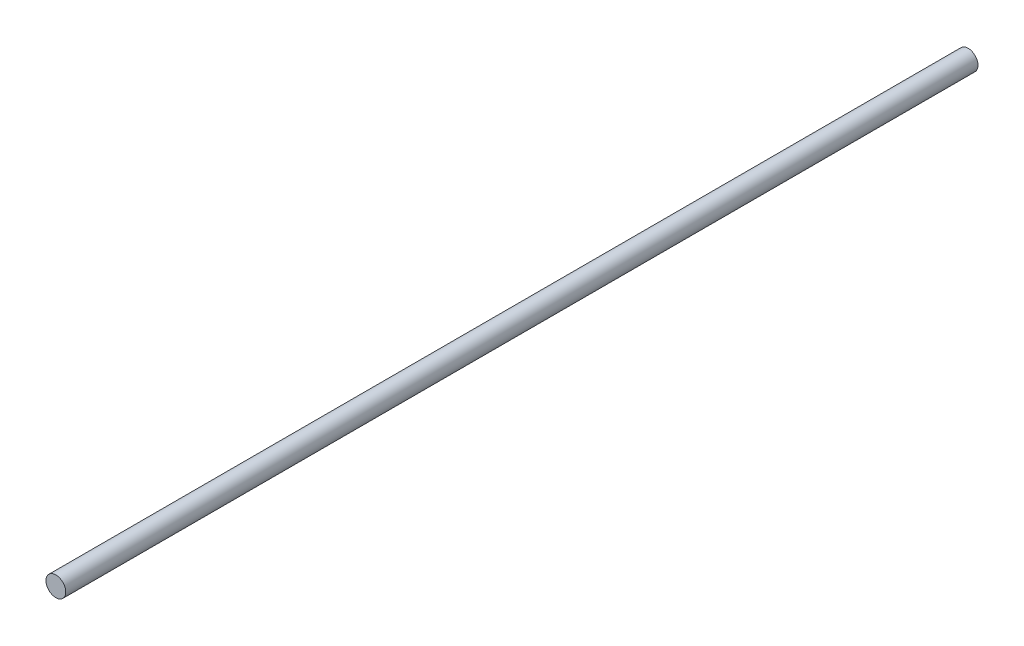
from build123d import *

# Parameters (mm, degrees)
SKETCH1_R           = 3.302
BOSS_EXTRUDE1_DEPTH = 304.8


with BuildPart() as part:
    # Sketch1 → Boss-Extrude1 (new body)
    with BuildSketch(Plane.XY):
        Circle(SKETCH1_R)
    extrude(amount=BOSS_EXTRUDE1_DEPTH)


solid = part.part
